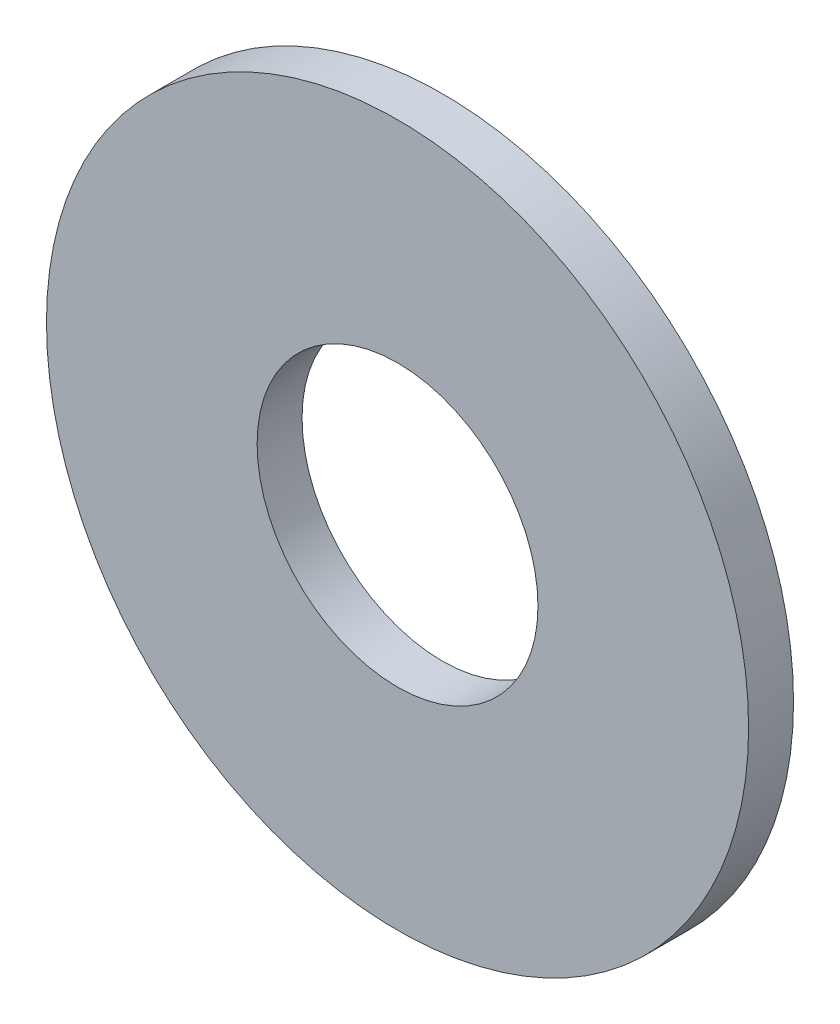
from build123d import *

# Parameters (mm, degrees)
SKETCH1_R      = 3.96875
SKETCH1_R_2    = 1.5875
EXTRUDE1_DEPTH = 0.508


with BuildPart() as part:
    # Sketch1 → Extrude1 (new body)
    with BuildSketch(Plane.XY):
        Circle(SKETCH1_R)
        Circle(SKETCH1_R_2, mode=Mode.SUBTRACT)
    extrude(amount=-EXTRUDE1_DEPTH)


solid = part.part
